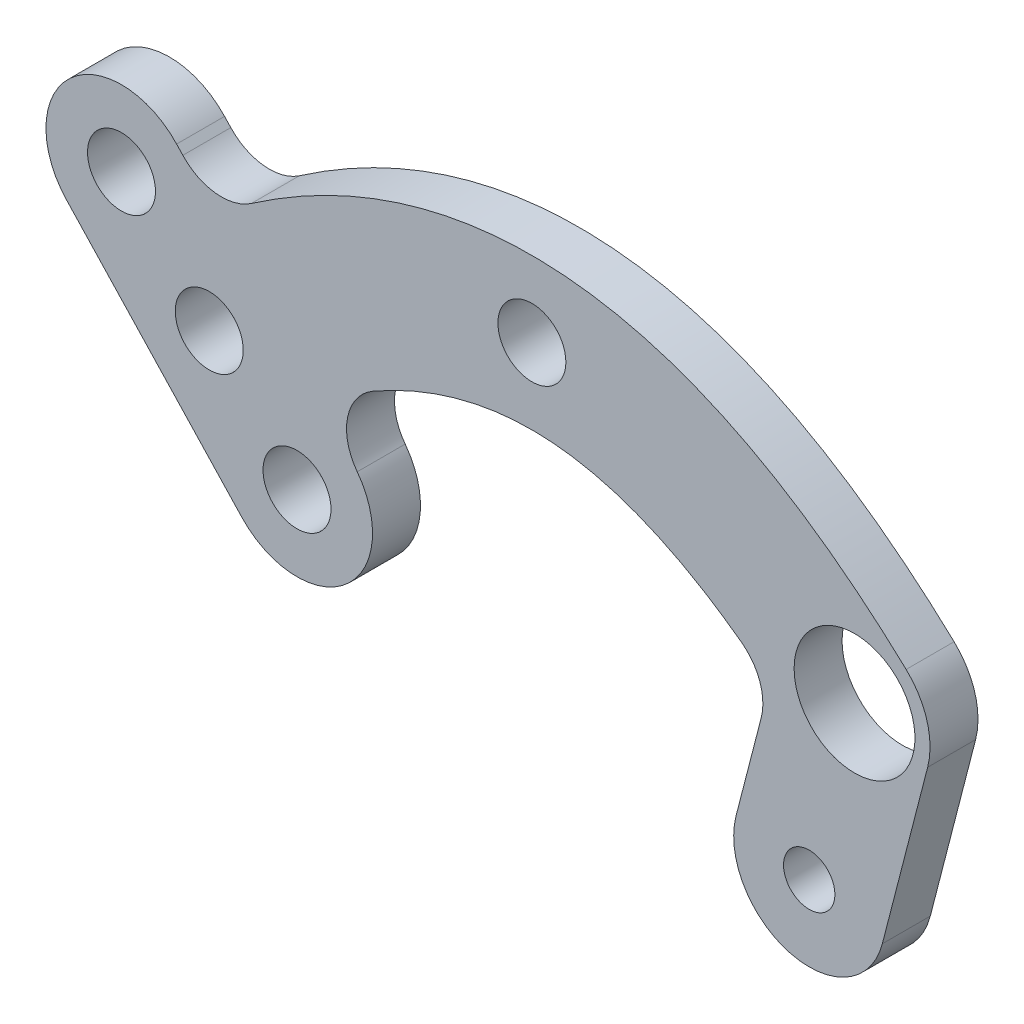
from build123d import *

# Parameters (mm, degrees)
BOSS_EXTRUDE1_DEPTH  = 1.5875
M4_CLEARANCE_HOLE1_D = 4.5
BOSS_EXTRUDE2_DEPTH  = 3.175
M3_CLEARANCE_HOLE1_D = 3.4
FILLET1_R            = 3.5
SKETCH8_R            = 4
CUT_EXTRUDE1_DEPTH   = 4.1750001


with BuildPart() as part:
    # Sketch2 → Boss-Extrude1 (new body, symmetric)
    with BuildSketch(Plane.XY):
        with BuildLine():
            add(Edge.make_bspline(
                [(-24.777431429, -6.350183234), (-24.299810251, -5.902972393), (-23.32289496, -5.01651393), (-22.058866471, -3.944003435), (-21.276036232, -3.316259916), (-20.98344634, -3.086723573)],
                knots=[0, 0, 0, 0, 0.03125, 0.0625, 0.081068463, 0.081068463, 0.081068463, 0.081068463], degree=3))
            Line((-24.777431429, -6.350183234), (-21.36, -10))
            add(Edge.make_bspline(
                [(-21.36, -10), (-20.09052587, -8.81135381), (-18.821051739, -7.728673603), (-17.551577609, -6.751959378)],
                knots=[0, 0, 0, 0, 0.089148464, 0.089148464, 0.089148464, 0.089148464], degree=3))
            Line((-17.551577609, -6.751959378), (-20.98344634, -3.086723573))
        make_face()
        with BuildLine():
            Line((-21.36, -10), (-24.777431429, -6.350183234))
            ThreePointArc((-24.777431429, -6.350183234), (-26.357299125, -9.8356788), (-25.009816701, -13.417431499))
            ThreePointArc((-25.009816701, -13.417431499), (-21.5243212, -14.997299125), (-17.942568571, -13.649816766))
            Line((-17.942568571, -13.649816766), (-21.36, -10))
        make_face()
        with BuildLine():
            ThreePointArc((-25.009816701, -13.417431499), (-26.357299125, -9.8356788), (-24.777431429, -6.350183234))
            add(Edge.make_bspline(
                [(-24.777431429, -6.350183234), (-24.299810251, -5.902972393), (-23.32289496, -5.01651393), (-22.058866471, -3.944003435), (-21.276036232, -3.316259916), (-20.98344634, -3.086723573)],
                knots=[0, 0, 0, 0, 0.03125, 0.0625, 0.081068463, 0.081068463, 0.081068463, 0.081068463], degree=3))
            Line((-20.98344634, -3.086723573), (-21.127614663, -2.932751805))
            Line((-21.127614663, -2.932751805), (-23.519816663, -0.377880068))
            ThreePointArc((-23.519816663, -0.377880068), (-30.587064859, -0.145494731), (-30.819450196, -7.212742926))
            Line((-30.819450196, -7.212742926), (-28.427248195, -9.767614663))
            Line((-28.427248195, -9.767614663), (-25.009816701, -13.417431499))
        make_face()
        with BuildLine():
            add(Edge.make_bspline(
                [(-21.36, -10), (-20.09052587, -8.81135381), (-18.821051739, -7.728673603), (-17.551577609, -6.751959378)],
                knots=[0, 0, 0, 0, 0.089148464, 0.089148464, 0.089148464, 0.089148464], degree=3))
            Line((-21.36, -10), (-17.942568571, -13.649816766))
            add(Edge.make_bspline(
                [(-17.942568571, -13.649816766), (-17.543072686, -13.275756949), (-16.7212792, -12.530114496), (-15.44829951, -11.450473224), (-14.582019434, -10.770813046), (-14.116024052, -10.421130577)],
                knots=[0, 0, 0, 0, 0.03125, 0.0625, 0.099339971, 0.099339971, 0.099339971, 0.099339971], degree=3))
            Line((-14.116024052, -10.421130577), (-14.292751805, -10.232385337))
            Line((-14.292751805, -10.232385337), (-17.551577609, -6.751959378))
        make_face()
        with BuildLine():
            ThreePointArc((-17.942568571, -13.649816766), (-21.5243212, -14.997299125), (-25.009816701, -13.417431499))
            Line((-25.009816701, -13.417431499), (-21.592385337, -17.067248195))
            Line((-21.592385337, -17.067248195), (-19.200183337, -19.622119932))
            ThreePointArc((-19.200183337, -19.622119932), (-12.132935141, -19.854505269), (-11.900549804, -12.787257074))
            Line((-11.900549804, -12.787257074), (-14.116024052, -10.421130577))
            add(Edge.make_bspline(
                [(-17.942568571, -13.649816766), (-17.543072686, -13.275756949), (-16.7212792, -12.530114496), (-15.44829951, -11.450473224), (-14.582019434, -10.770813046), (-14.116024052, -10.421130577)],
                knots=[0, 0, 0, 0, 0.03125, 0.0625, 0.099339971, 0.099339971, 0.099339971, 0.099339971], degree=3))
        make_face()
        with BuildLine():
            add(Edge.make_bspline(
                [(-20.98344634, -3.086723573), (-20.291201445, -2.543658465), (-18.603117827, -1.28817338), (-15.885096675, 0.462779531), (-11.785009924, 2.624744664), (-6.509375137, 4.48808894), (0, 5.25595553), (6.509375137, 4.48808894), (11.785009924, 2.624744664), (15.885096675, 0.462779531), (18.901874802, -1.480633029), (21.37388106, -3.362802893), (23.32289496, -5.01651393), (24.299810251, -5.902972393), (24.777431429, -6.350183234)],
                knots=[0.081068463, 0.081068463, 0.081068463, 0.081068463, 0.125, 0.1875, 0.25, 0.375, 0.5, 0.625, 0.75, 0.8125, 0.875, 0.9375, 0.96875, 1, 1, 1, 1], degree=3))
            Line((-20.98344634, -3.086723573), (-17.551577609, -6.751959378))
            Line((-17.551577609, -6.751959378), (-14.292751805, -10.232385337))
            Line((-14.292751805, -10.232385337), (-14.116024052, -10.421130577))
            add(Edge.make_bspline(
                [(-14.116024052, -10.421130577), (-13.791445759, -10.177567349), (-12.680801028, -9.370838959), (-10.815202086, -8.171392792), (-7.794818062, -6.582915934), (-4.170679183, -5.321481205), (0, -4.839259398), (4.170679183, -5.321481205), (7.794818062, -6.582915934), (10.815202086, -8.171392792), (13.136984474, -9.664132159), (15.119482265, -11.171596294), (16.7212792, -12.530114496), (17.543072686, -13.275756949), (17.942568571, -13.649816766)],
                knots=[0.099339971, 0.099339971, 0.099339971, 0.099339971, 0.125, 0.1875, 0.25, 0.375, 0.5, 0.625, 0.75, 0.8125, 0.875, 0.9375, 0.96875, 1, 1, 1, 1], degree=3))
            ThreePointArc((17.942568571, -13.649816766), (25.009816766, -13.417431429), (24.777431429, -6.350183234))
        make_face()
    extrude(amount=BOSS_EXTRUDE1_DEPTH, both=True)

    # M4 Clearance Hole1 (through all)
    with Locations(Plane.XY.offset(1.5875)):
        with Locations((-21.359999999, -9.999999999), (0, 0), (-15.550366571, -16.204688503), (-27.169633429, -3.795311497)):
            Hole(M4_CLEARANCE_HOLE1_D / 2)

    # Sketch5 → Boss-Extrude2 (add)
    with BuildSketch(Plane(origin=(0, 0, -1.5875), x_dir=(-1, 0, 0), z_dir=(0, 0, -1))):
        with BuildLine():
            ThreePointArc((-23.201229183, -22.868950039), (-17.11, -26.460179221), (-13.518770817, -20.368950039))
            Line((-13.518770817, -20.368950039), (-16.518770817, -8.75))
            ThreePointArc((-16.518770817, -8.75), (-22.61, -5.158770817), (-26.201229183, -11.25))
            Line((-26.201229183, -11.25), (-23.201229183, -22.868950039))
        make_face()
    extrude(amount=-BOSS_EXTRUDE2_DEPTH)

    # M3 Clearance Hole1 (through all)
    with Locations(Plane(origin=(0, 0, -1.5875), x_dir=(-1, 0, 0), z_dir=(0, 0, -1))):
        with Locations((-18.36, -21.618950039)):
            Hole(M3_CLEARANCE_HOLE1_D / 2)

    # Fillet1
    fillet1_edges = [part.edges().sort_by_distance(p)[0] for p in [
        (15.75315909, -11.715201468, -0.79375),
        (-20.98344634, -3.086723573, -0.79375),
        (-14.116024052, -10.421130577, 0.79375),
    ]]
    fillet(fillet1_edges, radius=FILLET1_R)

    # Sketch8 → Cut-Extrude1 (cut, through all)
    with BuildSketch(Plane(origin=(0, 0, -1.5875), x_dir=(-1, 0, 0), z_dir=(0, 0, -1))):
        with Locations((-21.36, -10)):
            Circle(SKETCH8_R)
    extrude(amount=-CUT_EXTRUDE1_DEPTH, mode=Mode.SUBTRACT)


solid = part.part
